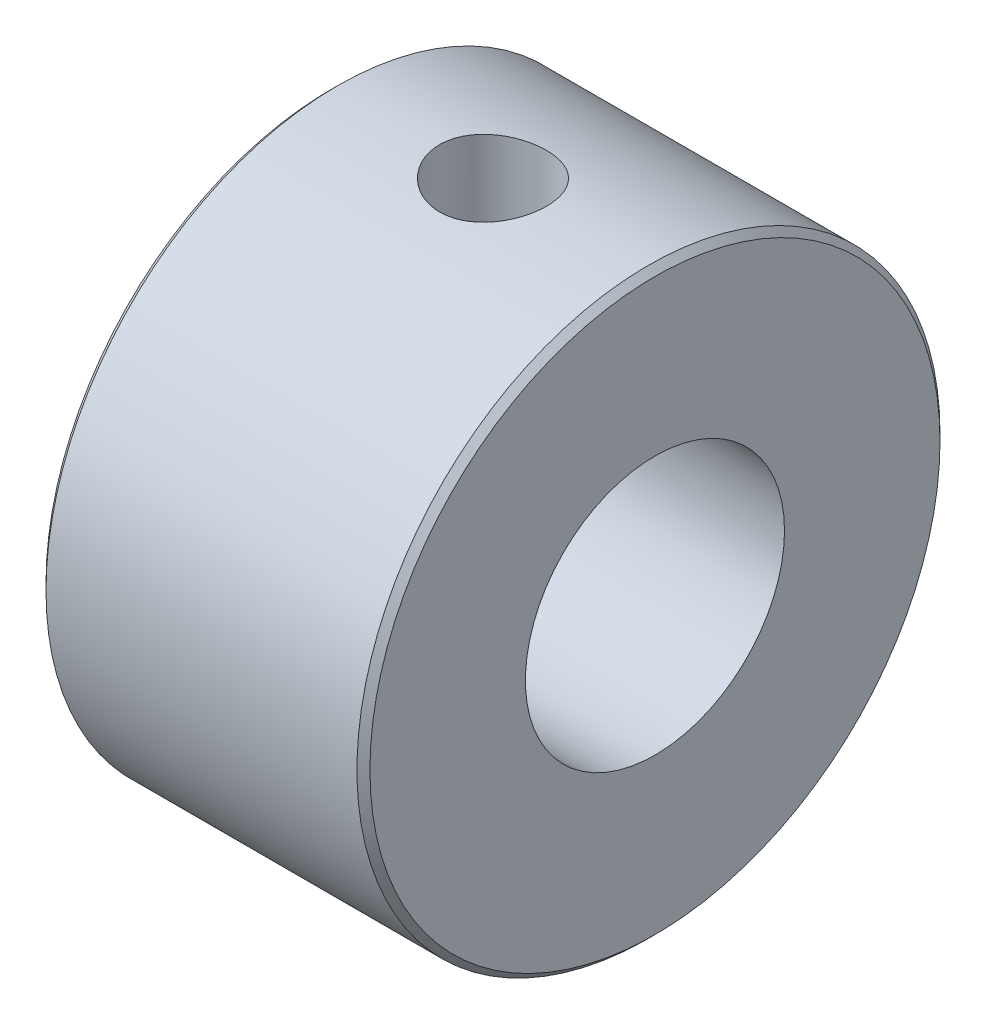
from build123d import *

# Parameters (mm, degrees)
SKETCH1_W              = 10
SKETCH1_H              = 5
CHAMFER1_SIZE          = 0.2
M4_TAPPED_HOLE1_REACH  = 22.736
M4_TAPPED_HOLE1_BORE_R = 1.65


with BuildPart() as part:
    # Sketch1 → Revolve1 (revolve)
    with BuildSketch(Plane.XY, mode=Mode.PRIVATE) as revolve1_sk:
        with Locations((0, 6.5)):
            Rectangle(SKETCH1_W, SKETCH1_H)
    revolve(revolve1_sk.sketch.rotate(Axis((0, 0, 0), (-1, 0, 0)), 90), axis=Axis((0, 0, 0), (-1, 0, 0)))

    # Chamfer1
    chamfer1_edges = [part.edges().sort_by_distance(p)[0] for p in [
        (5, 0, 9),
        (-5, 0, 9),
    ]]
    chamfer(chamfer1_edges, length=CHAMFER1_SIZE)

    # M4 Tapped Hole1 bore → M4 Tapped Hole1 (cut, up to next)
    with BuildSketch(Plane(origin=(0, 9, 0), x_dir=(1, 0, 0), z_dir=(0, 1, 0)), mode=Mode.PRIVATE) as m4_tapped_hole1_sk1:
        Circle(M4_TAPPED_HOLE1_BORE_R)
    m4_tapped_hole1_tool1 = extrude(m4_tapped_hole1_sk1.sketch, amount=-M4_TAPPED_HOLE1_REACH, mode=Mode.PRIVATE) & part.part
    add(m4_tapped_hole1_tool1.solids().sort_by_distance((0, 9, 0))[0], mode=Mode.SUBTRACT)


solid = part.part
